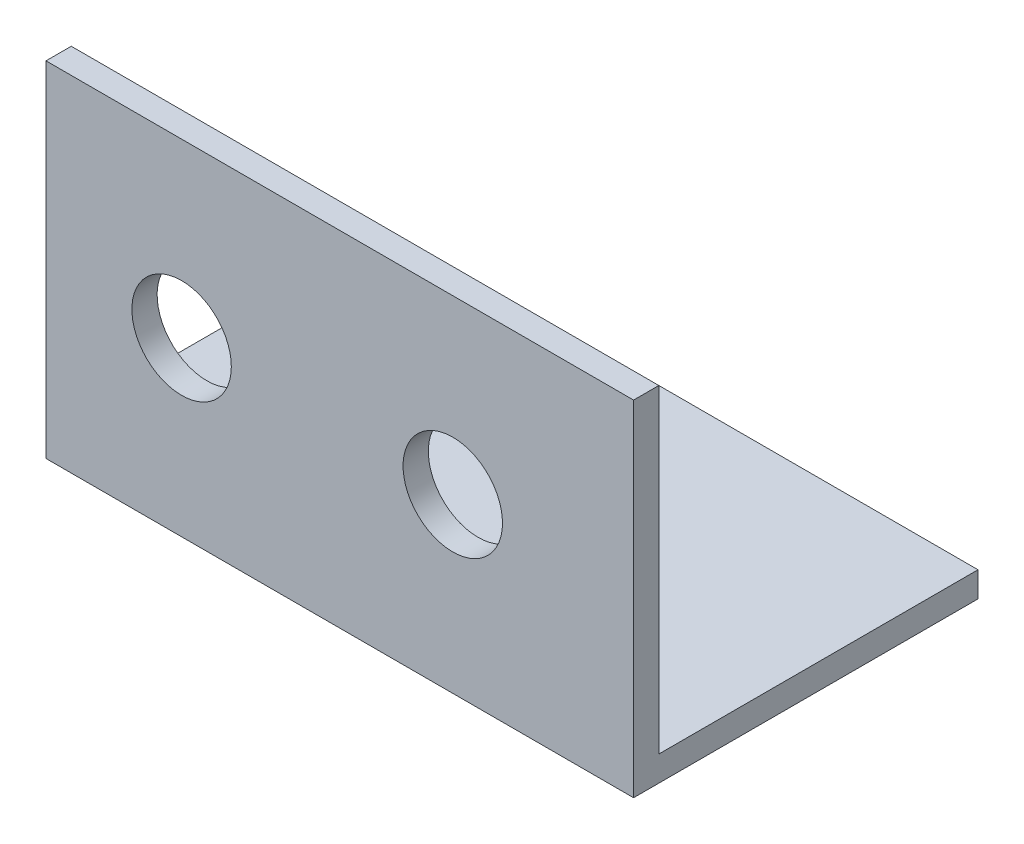
from build123d import *

# Parameters (mm, degrees)
BOSS_EXTRUDE1_DEPTH = 65
SKETCH2_R           = 5.5
CUT_EXTRUDE1_DEPTH  = 65


with BuildPart() as part:
    # Sketch1 → Boss-Extrude1 (new body)
    with BuildSketch(Plane(origin=(0, 0, 0), x_dir=(0, 0, -1), z_dir=(1, 0, 0))):
        Polygon((0, 35.306), (0, 0), (35.306, 0), (35.306, -2.794), (-2.794, -2.794), (-2.794, 35.306), align=None)
    extrude(amount=BOSS_EXTRUDE1_DEPTH)

    # Sketch2 → Cut-Extrude1 (cut)
    with BuildSketch(Plane.XY.offset(2.794)):
        with Locations((15, 16.256)):
            Circle(SKETCH2_R)
        with Locations((45, 16.256)):
            Circle(SKETCH2_R)
    extrude(amount=-CUT_EXTRUDE1_DEPTH, mode=Mode.SUBTRACT)


solid = part.part
